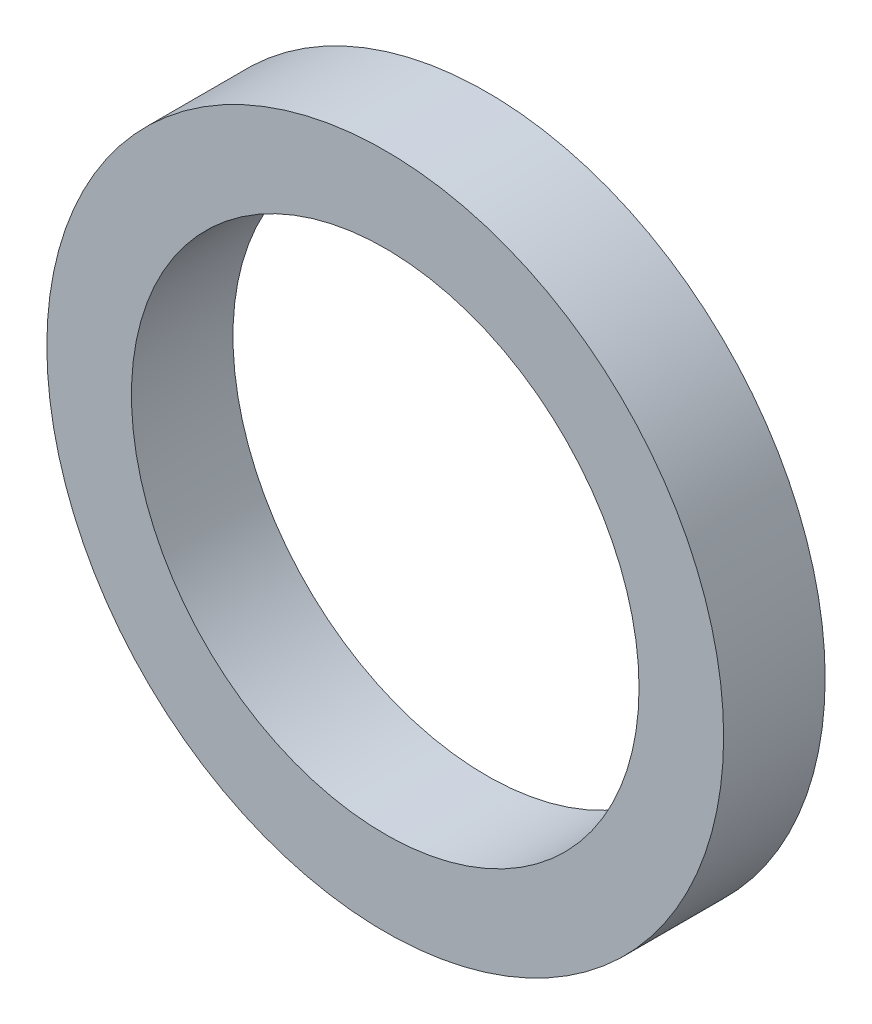
from build123d import *

# Parameters (mm, degrees)
SKETCH1_R           = 6.35
SKETCH1_R_2         = 4.7625
BOSS_EXTRUDE1_DEPTH = 1.905


with BuildPart() as part:
    # Sketch1 → Boss-Extrude1 (new body)
    with BuildSketch(Plane.XY):
        Circle(SKETCH1_R)
        Circle(SKETCH1_R_2, mode=Mode.SUBTRACT)
    extrude(amount=BOSS_EXTRUDE1_DEPTH)


solid = part.part
